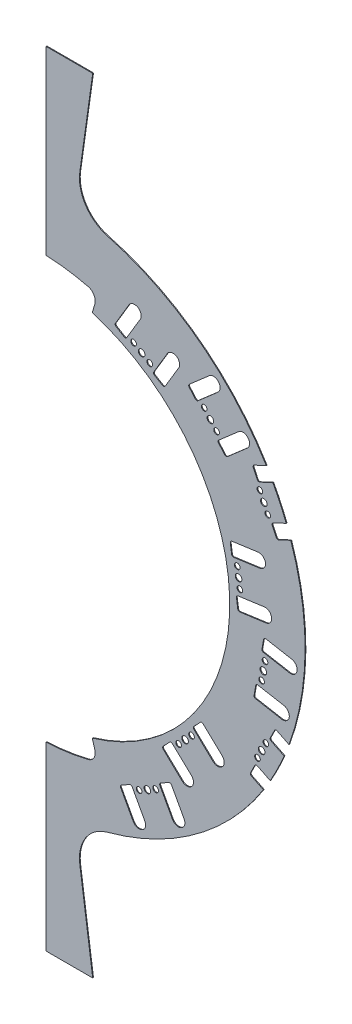
from build123d import *

# Parameters (mm, degrees)
EXTRUDE1_DEPTH                      = 0.205
EXTRUDE2_DEPTH                      = 0.41
FILLET3_R                           = 5
MOUSE_HOLE_CUT_EXTRUDE4_DEPTH       = 1.41
MOUSE_HOLE_CUT_EXTRUDE1_DEPTH       = 1.41
FILLET4_R                           = 1
MOUSE_HOLE_CUT_EXTRUDE3_DEPTH       = 1.41
FILLET2_R                           = 1
LADDER_MOUNT_HOLE_EXTRUDE7_DEPTH    = 1.41
LADDER_MOUNT_HOLE_EXTRUDE8_DEPTH    = 1.41
LADDER_MOUNT_HOLE_EXTRUDE11_DEPTH   = 1.41
LADDER_MOUNT_HOLE_CIRPATTERN1_COUNT = 3
LADDER_MOUNT_HOLE_CIRPATTERN1_ANGLE = 102.52629862
LADDER_MOUNT_HOLE_CIRPATTERN2_COUNT = 2
LADDER_MOUNT_HOLE_CIRPATTERN2_ANGLE = 51.26314931
MOUSE_HOLE_CIRPATTERN3_COUNT        = 3
MOUSE_HOLE_CIRPATTERN3_ANGLE        = 102.52629862
FILLET4_OF_MOUSE_HOLE_CIRPATTERN3_R = 1
MOUSE_HOLE_CIRPATTERN4_COUNT        = 2
MOUSE_HOLE_CIRPATTERN4_ANGLE        = 51.26314931
FILLET2_OF_MOUSE_HOLE_CIRPATTERN4_R = 1
EXTRUDE3_DEPTH                      = 0.41
CIRPATTERN1_COUNT                   = 3
CIRPATTERN1_ANGLE                   = 102.52629862
EXTRUDE4_DEPTH                      = 0.41
CIRPATTERN2_COUNT                   = 2
CIRPATTERN2_ANGLE                   = 51.26314931
SKETCH11_R                          = 1.5
SKETCH11_R_2                        = 1.75
EXTRUDE5_DEPTH                      = 1.41
CIRPATTERN3_COUNT                   = 3
CIRPATTERN3_ANGLE                   = 102.52629862
SKETCH12_R                          = 1.5
SKETCH12_R_2                        = 1.75
EXTRUDE6_DEPTH                      = 1.41
CIRPATTERN4_COUNT                   = 2
CIRPATTERN4_ANGLE                   = 51.26314931


with BuildPart() as part:
    # Sketch1 → Extrude1 (new body, symmetric)
    with BuildSketch(Plane.XY):
        with BuildLine():
            Line((22.373563978, 159.196179712), (29.232493618, 208))
            Line((29.232493618, 208), (4.5, 208))
            Line((4.5, 208), (4.5, 111.909561701))
            ThreePointArc((4.5, 111.909561701), (112, 0), (4.5, -111.909561701))
            Line((4.5, -111.909561701), (4.5, -208))
            Line((4.5, -208), (29.232493618, -208))
            Line((29.232493618, -208), (22.373563978, -159.196179712))
            ThreePointArc((22.373563978, -159.196179712), (25.492385871, -145.387319735), (36.971650618, -137.102505632))
            ThreePointArc((36.971650618, -137.102505632), (142, 0), (36.971650618, 137.102505632))
            ThreePointArc((36.971650618, 137.102505632), (25.492385871, 145.387319735), (22.373563978, 159.196179712))
        make_face()
    extrude(amount=EXTRUDE1_DEPTH, both=True)

    # Sketch2 → Extrude2 (add)
    with BuildSketch(Plane.XY.offset(0.205)):
        with BuildLine():
            Line((31.809718607, 107.387810305), (28.96956516, 97.799612957))
            ThreePointArc((28.96956516, 97.799612957), (102, 0), (28.96956516, -97.799612957))
            Line((28.96956516, -97.799612957), (31.809718607, -107.387810305))
            ThreePointArc((31.809718607, -107.387810305), (112, 0), (31.809718607, 107.387810305))
        make_face()
    extrude(amount=-EXTRUDE2_DEPTH)

    # Fillet3
    fillet3_edges = [part.edges().sort_by_distance(p)[0] for p in [
        (31.809718607, -107.387810305, 0),
        (31.809718607, 107.387810305, 0),
    ]]
    fillet(fillet3_edges, radius=FILLET3_R)

    # Sketch5 → Mouse Hole Cut-Extrude4 (cut, through all)
    with BuildSketch(Plane.XY.offset(0.205)):
        with BuildLine():
            Line((67.174381022, 82.47589017), (61.164862299, 86.065553765))
            Line((61.164862299, 86.065553765), (68.856998574, 98.943093884))
            ThreePointArc((68.856998574, 98.943093884), (73.656589733, 100.153021448), (74.866517297, 95.353430289))
            Line((74.866517297, 95.353430289), (67.174381022, 82.47589017))
        make_face()
        with BuildLine():
            Line((48.467560052, 111.122309653), (40.775423777, 98.244769534))
            Line((40.775423777, 98.244769534), (46.784942499, 94.655105938))
            Line((46.784942499, 94.655105938), (54.477078774, 107.532646058))
            ThreePointArc((54.477078774, 107.532646058), (53.267151211, 112.332237217), (48.467560052, 111.122309653))
        make_face()
    mouse_hole_cut_extrude4 = extrude(amount=-MOUSE_HOLE_CUT_EXTRUDE4_DEPTH, mode=Mode.SUBTRACT)

    # Sketch3 → Mouse Hole Cut-Extrude1 (cut, through all)
    with BuildSketch(Plane.XY.offset(0.205)):
        with BuildLine():
            Line((79.789058848, 90.023565589), (84.391221028, 84.749089001))
            Line((84.391221028, 84.749089001), (95.693670858, 94.610865101))
            ThreePointArc((95.693670858, 94.610865101), (96.029828062, 99.549184485), (91.091508678, 99.885341688))
            Line((91.091508678, 99.885341688), (79.789058848, 90.023565589))
        make_face()
        with BuildLine():
            Line((111.308149683, 76.715319537), (100.005699853, 66.853543437))
            Line((100.005699853, 66.853543437), (95.403537673, 72.128020025))
            Line((95.403537673, 72.128020025), (106.705987503, 81.989796124))
            ThreePointArc((106.705987503, 81.989796124), (111.644306887, 81.653638921), (111.308149683, 76.715319537))
        make_face()
    mouse_hole_cut_extrude1 = extrude(amount=-MOUSE_HOLE_CUT_EXTRUDE1_DEPTH, mode=Mode.SUBTRACT)

    # Fillet4
    fillet4_edges = [part.edges().sort_by_distance(p)[0] for p in [
        (79.789058848, 90.023565589, 0),
        (84.391221028, 84.749089001, 0),
        (67.174381022, 82.47589017, 0),
        (61.164862299, 86.065553765, 0),
        (46.784942499, 94.655105938, 0),
        (40.775423777, 98.244769534, 0),
        (100.005699853, 66.853543437, 0),
        (95.403537673, 72.128020025, 0),
    ]]
    fillet(fillet4_edges, radius=FILLET4_R)

    # Sketch4 → Mouse Hole Cut-Extrude3 (cut, through all)
    with BuildSketch(Plane.XY.offset(0.205)):
        with BuildLine():
            Line((124.125444221, 48.765892697), (127.089215564, 42.424279383))
            Line((127.089215564, 42.424279383), (134.39757133, 45.839860608))
            ThreePointArc((134.39757133, 45.839860608), (133.22262306, 49.150103815), (131.966156779, 52.43027241))
            Line((131.966156779, 52.43027241), (124.125444221, 48.765892697))
        make_face()
        with BuildLine():
            Line((114.069791453, 70.282080729), (121.37814722, 73.697661954))
            ThreePointArc((121.37814722, 73.697661954), (123.163892858, 70.672876666), (124.874275353, 67.604847127))
            Line((124.874275353, 67.604847127), (117.033562795, 63.940467414))
            Line((117.033562795, 63.940467414), (114.069791453, 70.282080729))
        make_face()
    mouse_hole_cut_extrude3 = extrude(amount=-MOUSE_HOLE_CUT_EXTRUDE3_DEPTH, mode=Mode.SUBTRACT)

    # Fillet2
    fillet2_edges = [part.edges().sort_by_distance(p)[0] for p in [
        (117.033562795, 63.940467414, 0),
        (114.069791453, 70.282080729, 0),
        (127.089215564, 42.424279383, 0),
        (124.125444221, 48.765892697, 0),
    ]]
    fillet(fillet2_edges, radius=FILLET2_R)

    # Sketch6 → Ladder Mount Hole Extrude7 (cut, through all)
    with BuildSketch(Plane.XY.offset(0.205)):
        with BuildLine():
            Line((59.837999061, 87.013049383), (48.248212954, 93.935972031))
            ThreePointArc((48.248212954, 93.935972031), (48.019785574, 94.243002228), (48.075366159, 94.621627911))
            Line((48.075366159, 94.621627911), (49.91327392, 97.698501497))
            ThreePointArc((49.91327392, 97.698501497), (50.220304116, 97.926928876), (50.598929799, 97.871348292))
            Line((50.598929799, 97.871348292), (62.188715907, 90.948425644))
            ThreePointArc((62.188715907, 90.948425644), (62.417143287, 90.641395447), (62.361562702, 90.262769764))
            Line((62.361562702, 90.262769764), (60.523654941, 87.185896178))
            ThreePointArc((60.523654941, 87.185896178), (60.216624744, 86.957468799), (59.837999061, 87.013049383))
        make_face()
    ladder_mount_hole_extrude7 = extrude(amount=-LADDER_MOUNT_HOLE_EXTRUDE7_DEPTH, mode=Mode.SUBTRACT)

    # Sketch7 → Ladder Mount Hole Extrude8 (cut, through all)
    with BuildSketch(Plane.XY.offset(0.205)):
        with BuildLine():
            Line((85.559795161, 83.612098018), (94.435393651, 73.439893171))
            ThreePointArc((94.435393651, 73.439893171), (94.778184973, 73.269773452), (95.140867848, 73.391870713))
            Line((95.140867848, 73.391870713), (97.841399861, 75.748177749))
            ThreePointArc((97.841399861, 75.748177749), (98.01151958, 76.090969072), (97.889422319, 76.453651947))
            Line((97.889422319, 76.453651947), (89.013823829, 86.625856794))
            ThreePointArc((89.013823829, 86.625856794), (88.671032507, 86.795976513), (88.308349631, 86.673879252))
            Line((88.308349631, 86.673879252), (85.607817619, 84.317572216))
            ThreePointArc((85.607817619, 84.317572216), (85.437697899, 83.974780893), (85.559795161, 83.612098018))
        make_face()
    ladder_mount_hole_extrude8 = extrude(amount=-LADDER_MOUNT_HOLE_EXTRUDE8_DEPTH, mode=Mode.SUBTRACT)

    # Sketch8 → Ladder Mount Hole Extrude11 (cut, through all)
    with BuildSketch(Plane.XY.offset(0.205)):
        with BuildLine():
            Line((119.309273033, 63.210319582), (125.025117764, 50.980065332))
            ThreePointArc((125.025117764, 50.980065332), (125.042138284, 50.597760596), (124.783843338, 50.315395))
            Line((124.783843338, 50.315395), (121.536937321, 48.797944072))
            ThreePointArc((121.536937321, 48.797944072), (121.154632584, 48.780923552), (120.872266988, 49.039218499))
            Line((120.872266988, 49.039218499), (115.156422257, 61.269472748))
            ThreePointArc((115.156422257, 61.269472748), (115.139401737, 61.651777485), (115.397696683, 61.934143081))
            Line((115.397696683, 61.934143081), (118.6446027, 63.451594008))
            ThreePointArc((118.6446027, 63.451594008), (119.026907436, 63.468614528), (119.309273033, 63.210319582))
        make_face()
    ladder_mount_hole_extrude11 = extrude(amount=-LADDER_MOUNT_HOLE_EXTRUDE11_DEPTH, mode=Mode.SUBTRACT)

    # Ladder Mount Hole CirPattern1: Ladder Mount Hole Extrude7, Ladder Mount Hole Extrude8 ×3 about axis
    ladder_mount_hole_cirpattern1_axis = Axis((0, 0, 0), (0, 0, -1))
    add([ladder_mount_hole_extrude7.rotate(ladder_mount_hole_cirpattern1_axis, i * LADDER_MOUNT_HOLE_CIRPATTERN1_ANGLE / (LADDER_MOUNT_HOLE_CIRPATTERN1_COUNT - 1)) for i in range(1, LADDER_MOUNT_HOLE_CIRPATTERN1_COUNT)], mode=Mode.SUBTRACT)
    add([ladder_mount_hole_extrude8.rotate(ladder_mount_hole_cirpattern1_axis, i * LADDER_MOUNT_HOLE_CIRPATTERN1_ANGLE / (LADDER_MOUNT_HOLE_CIRPATTERN1_COUNT - 1)) for i in range(1, LADDER_MOUNT_HOLE_CIRPATTERN1_COUNT)], mode=Mode.SUBTRACT)

    # Ladder Mount Hole CirPattern2: Ladder Mount Hole Extrude11 ×2 about axis
    ladder_mount_hole_cirpattern2_axis = Axis((0, 0, 0), (0, 0, -1))
    for i in range(1, LADDER_MOUNT_HOLE_CIRPATTERN2_COUNT):
        add(ladder_mount_hole_extrude11.rotate(ladder_mount_hole_cirpattern2_axis, i * LADDER_MOUNT_HOLE_CIRPATTERN2_ANGLE / (LADDER_MOUNT_HOLE_CIRPATTERN2_COUNT - 1)), mode=Mode.SUBTRACT)

    # Mouse Hole CirPattern3: Mouse Hole Cut-Extrude4, Mouse Hole Cut-Extrude1 ×3 about axis
    mouse_hole_cirpattern3_axis = Axis((0, 0, 0), (0, 0, -1))
    add([mouse_hole_cut_extrude4.rotate(mouse_hole_cirpattern3_axis, i * MOUSE_HOLE_CIRPATTERN3_ANGLE / (MOUSE_HOLE_CIRPATTERN3_COUNT - 1)) for i in range(1, MOUSE_HOLE_CIRPATTERN3_COUNT)], mode=Mode.SUBTRACT)
    add([mouse_hole_cut_extrude1.rotate(mouse_hole_cirpattern3_axis, i * MOUSE_HOLE_CIRPATTERN3_ANGLE / (MOUSE_HOLE_CIRPATTERN3_COUNT - 1)) for i in range(1, MOUSE_HOLE_CIRPATTERN3_COUNT)], mode=Mode.SUBTRACT)

    # Fillet4 of Mouse Hole CirPattern3
    fillet4_of_mouse_hole_cirpattern3_edges = [part.edges().sort_by_distance(p)[0] for p in [
        (120.148474426, -5.905960245, 0),
        (118.914011964, -12.796250691, 0),
        (106.367510493, -0.789073105, 0),
        (105.40712588, 6.144732588, 0),
        (103.109062699, 22.736339069, 0),
        (102.148678086, 29.670144762, 0),
        (114.725657185, -36.174021848, 0),
        (115.960119646, -29.283731402, 0),
        (70.575428818, -97.414809553, 0),
        (64.428350514, -100.763455297, 0),
        (65.943382614, -83.463406439, 0),
        (70.750990608, -78.375488852, 0),
        (82.254909739, -66.200828913, 0),
        (87.062517734, -61.112911326, 0),
        (43.572191979, -112.124931926, 0),
        (49.719270284, -108.776286182, 0),
    ]]
    fillet(fillet4_of_mouse_hole_cirpattern3_edges, radius=FILLET4_OF_MOUSE_HOLE_CIRPATTERN3_R)

    # Mouse Hole CirPattern4: Mouse Hole Cut-Extrude3 ×2 about axis
    mouse_hole_cirpattern4_axis = Axis((0, 0, 0), (0, 0, -1))
    for i in range(1, MOUSE_HOLE_CIRPATTERN4_COUNT):
        add(mouse_hole_cut_extrude3.rotate(mouse_hole_cirpattern4_axis, i * MOUSE_HOLE_CIRPATTERN4_ANGLE / (MOUSE_HOLE_CIRPATTERN4_COUNT - 1)), mode=Mode.SUBTRACT)

    # Fillet2 of Mouse Hole CirPattern4
    fillet2_of_mouse_hole_cirpattern4_edges = [part.edges().sort_by_distance(p)[0] for p in [
        (123.108467123, -51.279074838, 0),
        (126.200540242, -44.999020394, 0),
        (112.617504757, -72.586402419, 0),
        (115.709577875, -66.306347974, 0),
    ]]
    fillet(fillet2_of_mouse_hole_cirpattern4_edges, radius=FILLET2_OF_MOUSE_HOLE_CIRPATTERN4_R)

    # Sketch9 → Extrude3 (add)
    with BuildSketch(Plane.XY.offset(0.205)):
        with BuildLine():
            Line((49.91327392, 97.698501497), (48.075366159, 94.621627911))
            ThreePointArc((48.075366159, 94.621627911), (48.019785574, 94.243002228), (48.248212954, 93.935972031))
            Line((48.248212954, 93.935972031), (59.837999061, 87.013049383))
            ThreePointArc((59.837999061, 87.013049383), (60.216624744, 86.957468799), (60.523654941, 87.185896178))
            Line((60.523654941, 87.185896178), (62.361562702, 90.262769764))
            ThreePointArc((62.361562702, 90.262769764), (62.417143287, 90.641395447), (62.188715907, 90.948425644))
            Line((62.188715907, 90.948425644), (50.598929799, 97.871348292))
            ThreePointArc((50.598929799, 97.871348292), (50.220304116, 97.926928876), (49.91327392, 97.698501497))
        make_face()
        with BuildLine():
            Line((97.889422319, 76.453651947), (89.013823829, 86.625856794))
            ThreePointArc((89.013823829, 86.625856794), (88.671032507, 86.795976513), (88.308349631, 86.673879252))
            Line((88.308349631, 86.673879252), (85.607817619, 84.317572216))
            ThreePointArc((85.607817619, 84.317572216), (85.437697899, 83.974780893), (85.559795161, 83.612098018))
            Line((85.559795161, 83.612098018), (94.435393651, 73.439893171))
            ThreePointArc((94.435393651, 73.439893171), (94.778184973, 73.269773452), (95.140867848, 73.391870713))
            Line((95.140867848, 73.391870713), (97.841399861, 75.748177749))
            ThreePointArc((97.841399861, 75.748177749), (98.01151958, 76.090969072), (97.889422319, 76.453651947))
        make_face()
    extrude3 = extrude(amount=-EXTRUDE3_DEPTH)

    # CirPattern1: Extrude3 ×3 about axis
    cirpattern1_axis = Axis((0, 0, -47.622928889), (0, 0, -1))
    for i in range(1, CIRPATTERN1_COUNT):
        add(extrude3.rotate(cirpattern1_axis, i * CIRPATTERN1_ANGLE / (CIRPATTERN1_COUNT - 1)))

    # Sketch10 → Extrude4 (add)
    with BuildSketch(Plane.XY.offset(0.205)):
        with BuildLine():
            Line((125.025117764, 50.980065332), (119.309273033, 63.210319582))
            ThreePointArc((119.309273033, 63.210319582), (119.026907436, 63.468614528), (118.6446027, 63.451594008))
            Line((118.6446027, 63.451594008), (115.397696683, 61.934143081))
            ThreePointArc((115.397696683, 61.934143081), (115.139401737, 61.651777485), (115.156422257, 61.269472748))
            Line((115.156422257, 61.269472748), (120.872266988, 49.039218499))
            ThreePointArc((120.872266988, 49.039218499), (121.154632584, 48.780923552), (121.536937321, 48.797944072))
            Line((121.536937321, 48.797944072), (124.783843338, 50.315395))
            ThreePointArc((124.783843338, 50.315395), (125.042138284, 50.597760596), (125.025117764, 50.980065332))
        make_face()
    extrude4 = extrude(amount=-EXTRUDE4_DEPTH)

    # CirPattern2: Extrude4 ×2 about axis
    cirpattern2_axis = Axis((0, 0, -47.622928889), (0, 0, -1))
    for i in range(1, CIRPATTERN2_COUNT):
        add(extrude4.rotate(cirpattern2_axis, i * CIRPATTERN2_ANGLE / (CIRPATTERN2_COUNT - 1)))

    # Sketch11 → Extrude5 (cut, through all)
    with BuildSketch(Plane.XY.offset(0.205)):
        with Locations((95.01186744, 76.265391706)):
            Circle(SKETCH11_R)
        with Locations((91.72460874, 80.032874983)):
            Circle(SKETCH11_R_2)
        with Locations((88.43735004, 83.800358259)):
            Circle(SKETCH11_R)
        with Locations((59.510977803, 89.878153412)):
            Circle(SKETCH11_R)
        with Locations((55.21846443, 92.442198837)):
            Circle(SKETCH11_R_2)
        with Locations((50.925951057, 95.006244263)):
            Circle(SKETCH11_R)
    extrude5 = extrude(amount=-EXTRUDE5_DEPTH, mode=Mode.SUBTRACT)

    # CirPattern3: Extrude5 ×3 about axis
    cirpattern3_axis = Axis((0, 0, 0), (0, 0, -1))
    for i in range(1, CIRPATTERN3_COUNT):
        add(extrude5.rotate(cirpattern3_axis, i * CIRPATTERN3_ANGLE / (CIRPATTERN3_COUNT - 1)), mode=Mode.SUBTRACT)

    # Sketch12 → Extrude6 (cut, through all)
    with BuildSketch(Plane.XY.offset(0.205)):
        with Locations((122.20774954, 51.595045244)):
            Circle(SKETCH12_R)
        with Locations((120.09077001, 56.12476904)):
            Circle(SKETCH12_R_2)
        with Locations((117.97379048, 60.654492836)):
            Circle(SKETCH12_R)
    extrude6 = extrude(amount=-EXTRUDE6_DEPTH, mode=Mode.SUBTRACT)

    # CirPattern4: Extrude6 ×2 about axis
    cirpattern4_axis = Axis((0, 0, 0), (0, 0, -1))
    for i in range(1, CIRPATTERN4_COUNT):
        add(extrude6.rotate(cirpattern4_axis, i * CIRPATTERN4_ANGLE / (CIRPATTERN4_COUNT - 1)), mode=Mode.SUBTRACT)


solid = part.part
